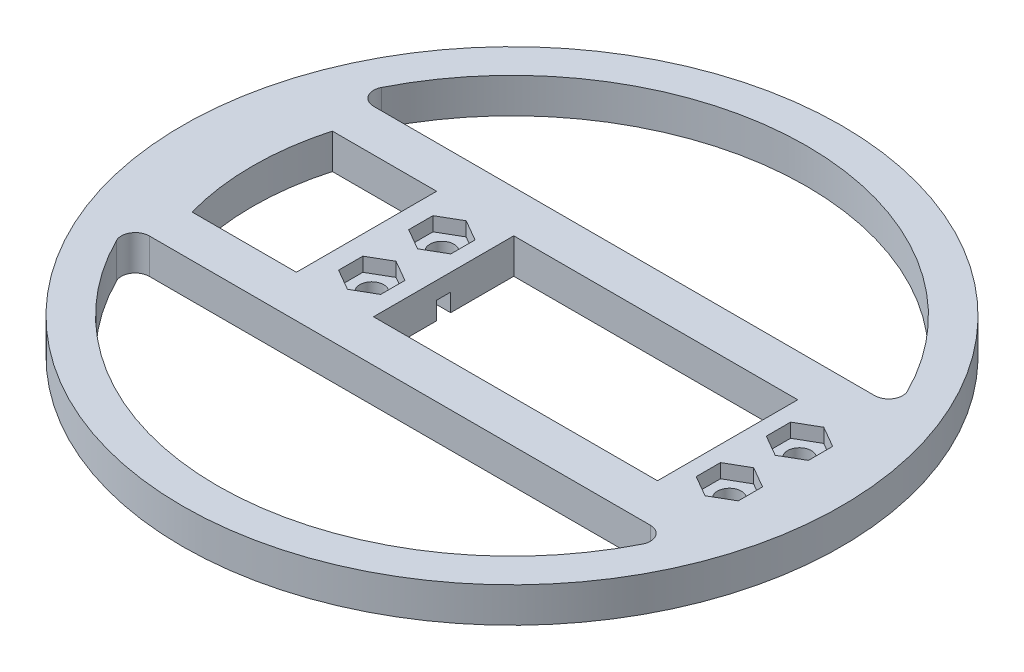
from build123d import *

# Parameters (mm, degrees)
SKETCH_1_R          = 47
SKETCH_1_R_2        = 1.7
SKETCH_1_W          = 40.5
SKETCH_1_H          = 20
EXTRUDE_1_DEPTH     = 5
CUT_EXTRUDE_1_DEPTH = 2
CUT_EXTRUDE_2_DEPTH = 1
CUT_EXTRUDE_3_DEPTH = 6
FILLET_1_R          = 2


with BuildPart() as part:
    # Эскиз1 → Бобышка-Вытянуть1 (new body)
    with BuildSketch(Plane(origin=(0, 0, 0), x_dir=(1, 0, 0), z_dir=(0, 1, 0))):
        Circle(SKETCH_1_R)
        with Locations((-15, 5)):
            Circle(SKETCH_1_R_2, mode=Mode.SUBTRACT)
        with Locations((-15, -5)):
            Circle(SKETCH_1_R_2, mode=Mode.SUBTRACT)
        with Locations((36, 5)):
            Circle(SKETCH_1_R_2, mode=Mode.SUBTRACT)
        with Locations((36, -5)):
            Circle(SKETCH_1_R_2, mode=Mode.SUBTRACT)
        with Locations((10.5, 0)):
            Rectangle(SKETCH_1_W, SKETCH_1_H, mode=Mode.SUBTRACT)
    extrude(amount=EXTRUDE_1_DEPTH)

    # Эскиз2 → Вырез-Вытянуть1 (cut)
    with BuildSketch(Plane(origin=(0, 5, 0), x_dir=(1, 0, 0), z_dir=(0, 1, 0))):
        Polygon((-12, 6.732050808), (-15, 8.464101615), (-18, 6.732050808), (-18, 3.267949192), (-15, 1.535898385), (-12, 3.267949192), align=None)
        Polygon((-12, -3.267949192), (-15, -1.535898385), (-18, -3.267949192), (-18, -6.732050808), (-15, -8.464101615), (-12, -6.732050808), align=None)
        Polygon((36, 8.464101615), (33, 6.732050808), (33, 3.267949192), (36, 1.535898385), (39, 3.267949192), (39, 6.732050808), align=None)
        Polygon((36, -1.535898385), (33, -3.267949192), (33, -6.732050808), (36, -8.464101615), (39, -6.732050808), (39, -3.267949192), align=None)
    extrude(amount=-CUT_EXTRUDE_1_DEPTH, mode=Mode.SUBTRACT)

    # Эскиз3 → Вырез-Вытянуть2 (cut, symmetric)
    with BuildSketch(Plane.XY):
        Polygon((27.412104095, 3.670718329), (30.75, 0), (38.308934037, 0), align=None)
        Polygon((-6.412104095, 3.670718329), (-9.75, 0), (-17.308934037, 0), align=None)
    extrude(amount=CUT_EXTRUDE_2_DEPTH, both=True, mode=Mode.SUBTRACT)

    # Эскиз4 → Вырез-Вытянуть3 (cut, through all)
    with BuildSketch(Plane(origin=(0, 5, 0), x_dir=(1, 0, 0), z_dir=(0, 1, 0))):
        with BuildLine():
            ThreePointArc((-38.832975678, -16), (0, -42), (38.832975678, -16))
            Line((38.832975678, -16), (-38.832975678, -16))
        make_face()
        with BuildLine():
            ThreePointArc((38.832975678, 16), (0, 42), (-38.832975678, 16))
            Line((-38.832975678, 16), (38.832975678, 16))
        make_face()
        with BuildLine():
            Line((-35.623026261, -10), (-20.75, -10))
            Line((-20.75, -10), (-20.75, 10))
            Line((-20.75, 10), (-35.623026261, 10))
            ThreePointArc((-35.623026261, 10), (-37, 0), (-35.623026261, -10))
        make_face()
    extrude(amount=-CUT_EXTRUDE_3_DEPTH, mode=Mode.SUBTRACT)

    # Скругление1
    fillet_1_edges = [part.edges().sort_by_distance(p)[0] for p in [
        (-38.832975678, 2.5, 16),
        (38.832975678, 2.5, 16),
        (38.832975678, 2.5, -16),
        (-38.832975678, 2.5, -16),
    ]]
    fillet(fillet_1_edges, radius=FILLET_1_R)


solid = part.part
